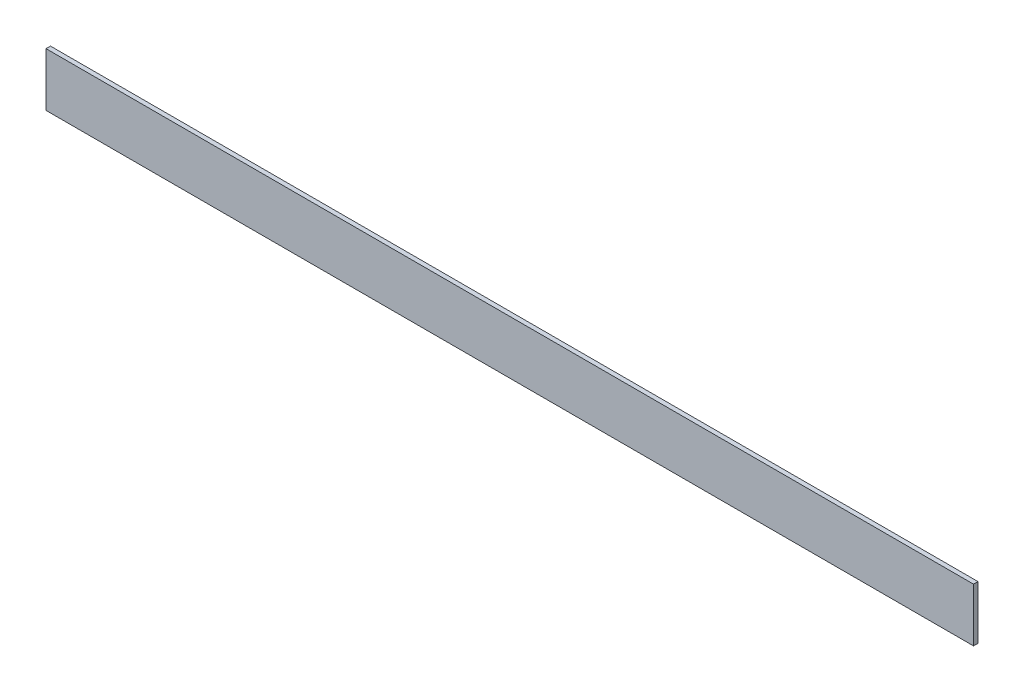
from build123d import *

# Parameters (mm, degrees)
SKETCH1_W           = 6.35
SKETCH1_H           = 76.2
BOSS_EXTRUDE1_DEPTH = 1320.8


with BuildPart() as part:
    # Sketch1 → Boss-Extrude1 (new body)
    with BuildSketch(Plane(origin=(0, 0, 0), x_dir=(0, 0, -1), z_dir=(1, 0, 0))):
        Rectangle(SKETCH1_W, SKETCH1_H)
    extrude(amount=BOSS_EXTRUDE1_DEPTH)


solid = part.part
